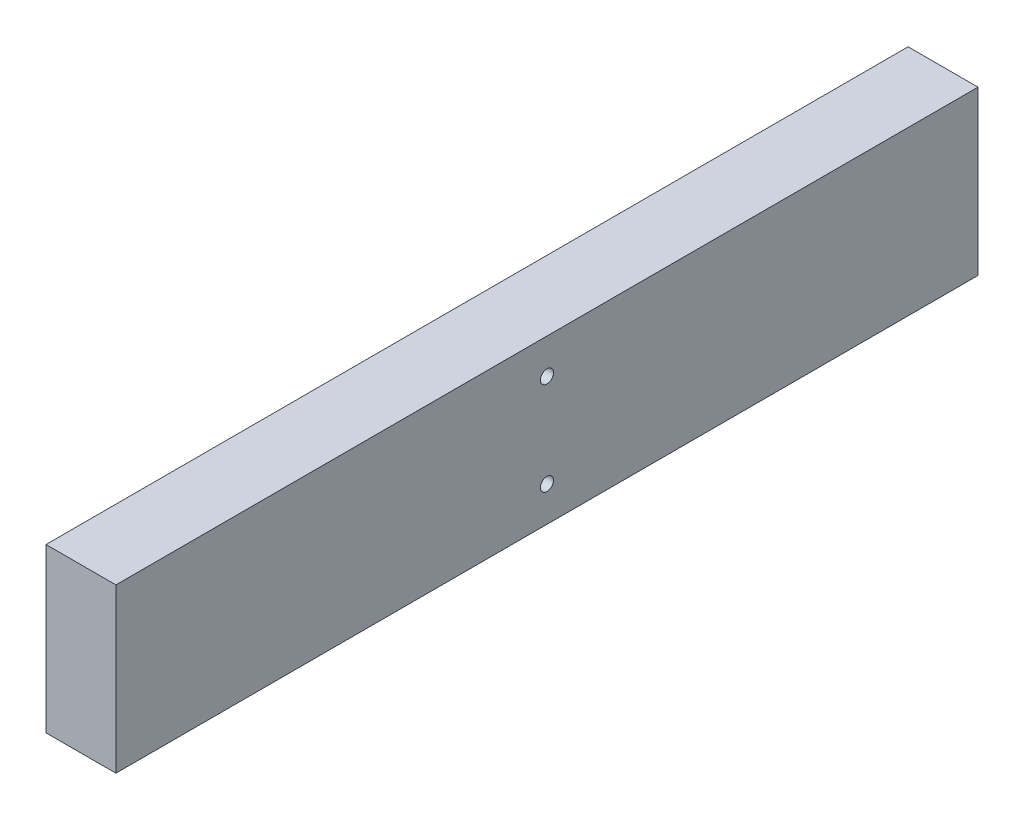
from build123d import *

# Parameters (mm, degrees)
SKETCH1_W                       = 38.1
SKETCH1_H                       = 88.9
BOSS_EXTRUDE1_DEPTH             = 469.9
F_9_32_0_28125_DIAMETER_HOLE1_D = 7.14375


with BuildPart() as part:
    # Sketch1 → Boss-Extrude1 (new body)
    with BuildSketch(Plane.XY):
        Rectangle(SKETCH1_W, SKETCH1_H)
    extrude(amount=BOSS_EXTRUDE1_DEPTH)

    # 9/32 (0.28125) Diameter Hole1 (through all)
    with Locations(Plane(origin=(19.05, 0, 0), x_dir=(0, 0, -1), z_dir=(1, 0, 0))):
        with Locations((-234.95, 25.4), (-234.95, -25.4)):
            Hole(F_9_32_0_28125_DIAMETER_HOLE1_D / 2)


solid = part.part
